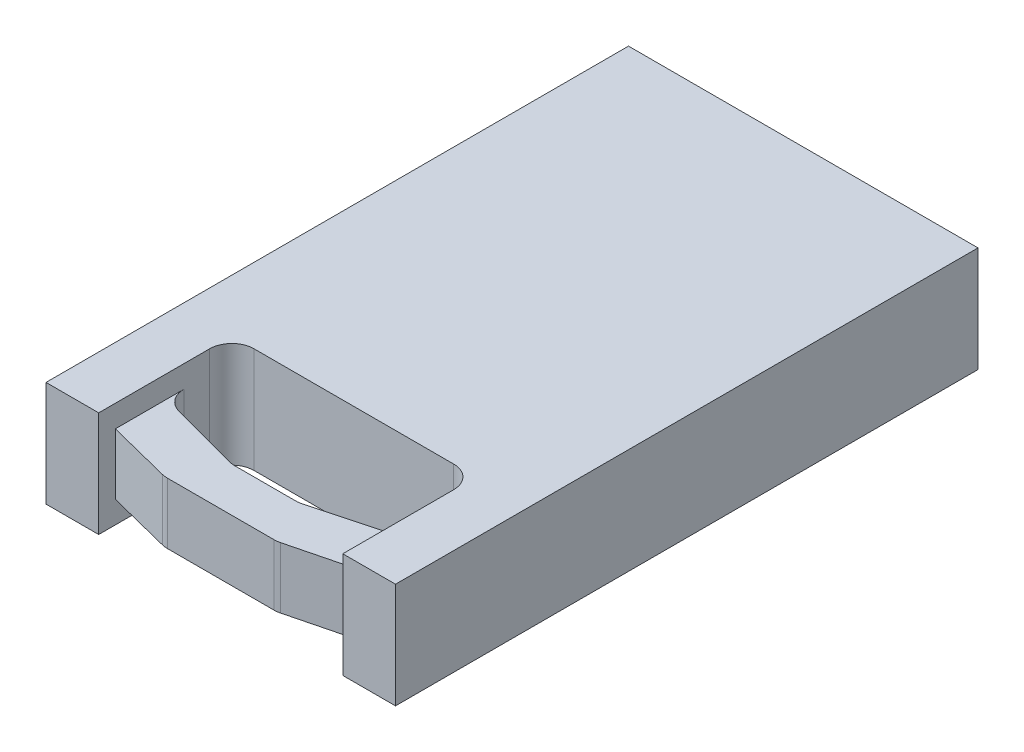
from build123d import *

# Parameters (mm, degrees)
SKETCH1_W           = 419.1
SKETCH1_H           = 333.375
BOSS_EXTRUDE1_DEPTH = 60.325
SKETCH2_W           = 139.7
SKETCH2_H           = 50.8
CUT_EXTRUDE1_DEPTH  = 61.325
CHAMFER1_SIZE       = 50.8
CHAMFER1_SIZE2      = 13.611818976
FILLET1_R           = 12.7
SKETCH3_W           = 139.7
SKETCH3_H           = 56.403006085
CUT_EXTRUDE2_DEPTH  = 12.7
SKETCH4_W           = 139.7
SKETCH4_H           = 56.128435861
CUT_EXTRUDE3_DEPTH  = 12.7
SKETCH5_OUTSIDE_W   = 528.882
SKETCH5_OUTSIDE_H   = 443.156
SKETCH5_OUTSIDE_W_2 = 200.025
SKETCH5_OUTSIDE_H_2 = 333.375
CUT_EXTRUDE4_DEPTH  = 61.325


with BuildPart() as part:
    # Sketch1 → Boss-Extrude1 (new body)
    with BuildSketch(Plane(origin=(0, 0, 0), x_dir=(1, 0, 0), z_dir=(0, 1, 0))):
        Rectangle(SKETCH1_W, SKETCH1_H)
    extrude(amount=BOSS_EXTRUDE1_DEPTH)

    # Sketch2 → Cut-Extrude1 (cut, through all)
    with BuildSketch(Plane(origin=(0, 60.325, 0), x_dir=(1, 0, 0), z_dir=(0, 1, 0))):
        with Locations((0, -115.8875)):
            Rectangle(SKETCH2_W, SKETCH2_H)
        Polygon((-69.85, -166.6875), (-69.85, -157.1625), (-32.169017961, -166.6875), align=None)
        Polygon((32.169017961, -166.6875), (69.85, -166.6875), (69.85, -157.1625), align=None)
    extrude(amount=-CUT_EXTRUDE1_DEPTH, mode=Mode.SUBTRACT)

    # Chamfer1
    chamfer1_edges = [part.edges().sort_by_distance(p)[0] for p in [
        (69.85, 30.1625, 141.2875),
        (-69.85, 30.1625, 141.2875),
    ]]
    chamfer1_side = [part.faces().sort_by_distance(p)[0] for p in [
        (0, 30.1625, 141.2875),
    ]]
    chamfer(chamfer1_edges, length=CHAMFER1_SIZE, length2=CHAMFER1_SIZE2, reference=chamfer1_side[0])

    # Fillet1
    fillet1_edges = [part.edges().sort_by_distance(p)[0] for p in [
        (69.85, 30.1625, 90.4875),
        (-69.85, 30.1625, 90.4875),
        (-32.169017961, 30.1625, 166.6875),
        (32.169017961, 30.1625, 166.6875),
        (69.85, 30.1625, 127.675681024),
        (-19.05, 30.1625, 141.2875),
        (19.05, 30.1625, 141.2875),
        (-69.85, 30.1625, 127.675681024),
    ]]
    fillet(fillet1_edges, radius=FILLET1_R)

    # Sketch3 → Cut-Extrude2 (cut)
    with BuildSketch(Plane(origin=(0, 60.325, 0), x_dir=(1, 0, 0), z_dir=(0, 1, 0))):
        with Locations((0, -138.485996957)):
            Rectangle(SKETCH3_W, SKETCH3_H)
    extrude(amount=-CUT_EXTRUDE2_DEPTH, mode=Mode.SUBTRACT)

    # Sketch4 → Cut-Extrude3 (cut)
    with BuildSketch(Plane.XZ):
        with Locations((0, 138.623282069)):
            Rectangle(SKETCH4_W, SKETCH4_H)
    extrude(amount=-CUT_EXTRUDE3_DEPTH, mode=Mode.SUBTRACT)

    # Sketch5 outside → Cut-Extrude4 (cut, through all)
    with BuildSketch(Plane(origin=(0, 60.325, 0), x_dir=(1, 0, 0), z_dir=(0, 1, 0))):
        Rectangle(SKETCH5_OUTSIDE_W, SKETCH5_OUTSIDE_H)
        Rectangle(SKETCH5_OUTSIDE_W_2, SKETCH5_OUTSIDE_H_2, mode=Mode.SUBTRACT)
    extrude(amount=-CUT_EXTRUDE4_DEPTH, mode=Mode.SUBTRACT)


solid = part.part
